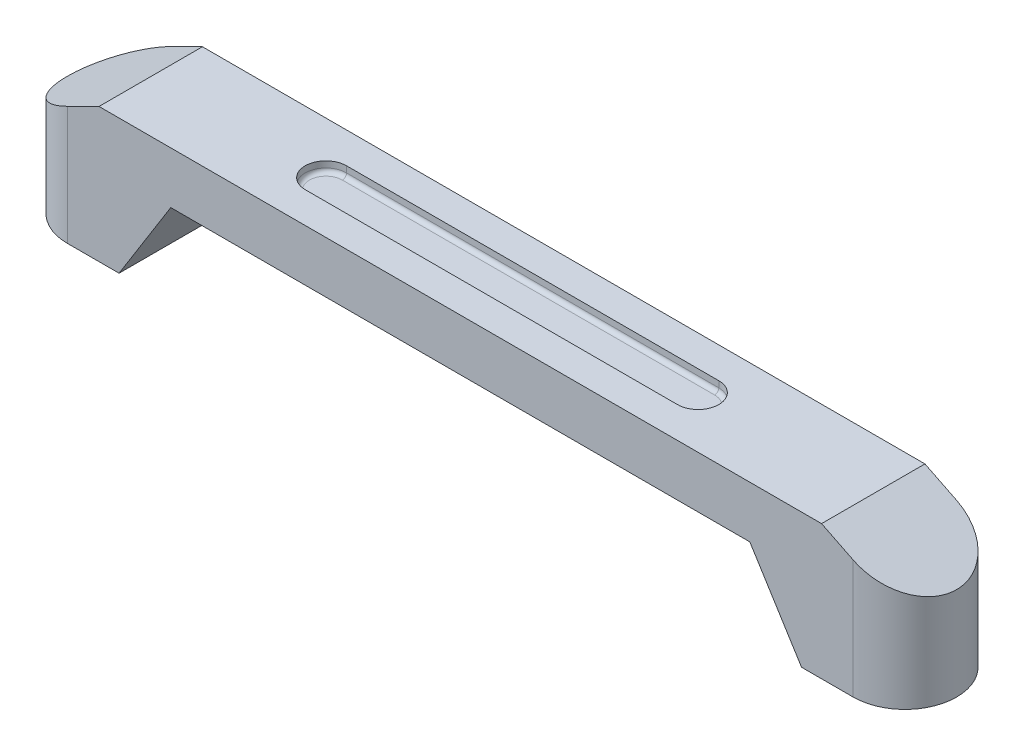
from build123d import *

# Parameters (mm, degrees)
EXTRUDE_1_DEPTH     = 6.5
CUT_EXTRUDE_1_REACH = 7
SKETCH_3_R          = 1
CUT_EXTRUDE_2_DEPTH = 3.5
CUT_EXTRUDE_3_DEPTH = 0.5
FILLET_1_R          = 0.2


with BuildPart() as part:
    # 草图1 → 凸台-拉伸1 (new body)
    with BuildSketch(Plane(origin=(0, 0, 0), x_dir=(1, 0, 0), z_dir=(0, 1, 0))):
        with BuildLine():
            Line((-19, 2.5), (19, 2.5))
            ThreePointArc((19, 2.5), (21.5, 0), (19, -2.5))
            Line((19, -2.5), (-19, -2.5))
            ThreePointArc((-19, -2.5), (-21.5, 0), (-19, 2.5))
        make_face()
    extrude(amount=EXTRUDE_1_DEPTH)

    # 草图2 → 切除-拉伸1 (cut, up to next)
    with BuildSketch(Plane.XY.offset(2.5), mode=Mode.PRIVATE) as cut_extrude_1_sk1:
        Polygon((17.468871126, 6.5), (21.5, 4.5), (21.5, 7.438332244), (17.468871126, 7.438332244), align=None)
    cut_extrude_1_tool1 = extrude(cut_extrude_1_sk1.sketch, amount=-CUT_EXTRUDE_1_REACH, mode=Mode.PRIVATE) & part.part
    add(cut_extrude_1_tool1.solids().sort_by_distance((19.83105, 6.383182, 2.5))[0], mode=Mode.SUBTRACT)
    # 草图2 → 切除-拉伸1 (cut, up to next)
    with BuildSketch(Plane.XY.offset(2.5), mode=Mode.PRIVATE) as cut_extrude_1_sk2:
        Polygon((14, 4), (16.5, 0), (16.5, -3.02965668), (-16.5, -3.02965668), (-16.5, 0), (-14, 4), align=None)
    cut_extrude_1_tool2 = extrude(cut_extrude_1_sk2.sketch, amount=-CUT_EXTRUDE_1_REACH, mode=Mode.PRIVATE) & part.part
    add(cut_extrude_1_tool2.solids().sort_by_distance((0, 0.386897, 2.5))[0], mode=Mode.SUBTRACT)
    # 草图2 → 切除-拉伸1 (cut, up to next)
    with BuildSketch(Plane.XY.offset(2.5), mode=Mode.PRIVATE) as cut_extrude_1_sk3:
        Polygon((-21.5, 7.438332244), (-17.468871126, 7.438332244), (-17.468871126, 6.5), (-21.5, 4.5), align=None)
    cut_extrude_1_tool3 = extrude(cut_extrude_1_sk3.sketch, amount=-CUT_EXTRUDE_1_REACH, mode=Mode.PRIVATE) & part.part
    add(cut_extrude_1_tool3.solids().sort_by_distance((-19.83105, 6.383182, 2.5))[0], mode=Mode.SUBTRACT)

    # 草图3 → 切除-拉伸2 (cut)
    with BuildSketch(Plane.XZ):
        with Locations((18.75, 0)):
            Circle(SKETCH_3_R)
        with Locations((-18.75, 0)):
            Circle(SKETCH_3_R)
    extrude(amount=-CUT_EXTRUDE_2_DEPTH, mode=Mode.SUBTRACT)

    # 草图4 → 切除-拉伸3 (cut)
    with BuildSketch(Plane(origin=(0, 6.5, 0), x_dir=(1, 0, 0), z_dir=(0, 1, 0))):
        with BuildLine():
            Line((-9, 1), (9, 1))
            ThreePointArc((9, 1), (10, 0), (9, -1))
            Line((9, -1), (-9, -1))
            ThreePointArc((-9, -1), (-10, 0), (-9, 1))
        make_face()
    extrude(amount=-CUT_EXTRUDE_3_DEPTH, mode=Mode.SUBTRACT)

    # 圆角1
    fillet_1_edges = [part.edges().sort_by_distance(p)[0] for p in [
        (-10, 6, 0),
        (0, 6, -1),
        (10, 6, 0),
        (0, 6, 1),
    ]]
    fillet(fillet_1_edges, radius=FILLET_1_R)


solid = part.part
